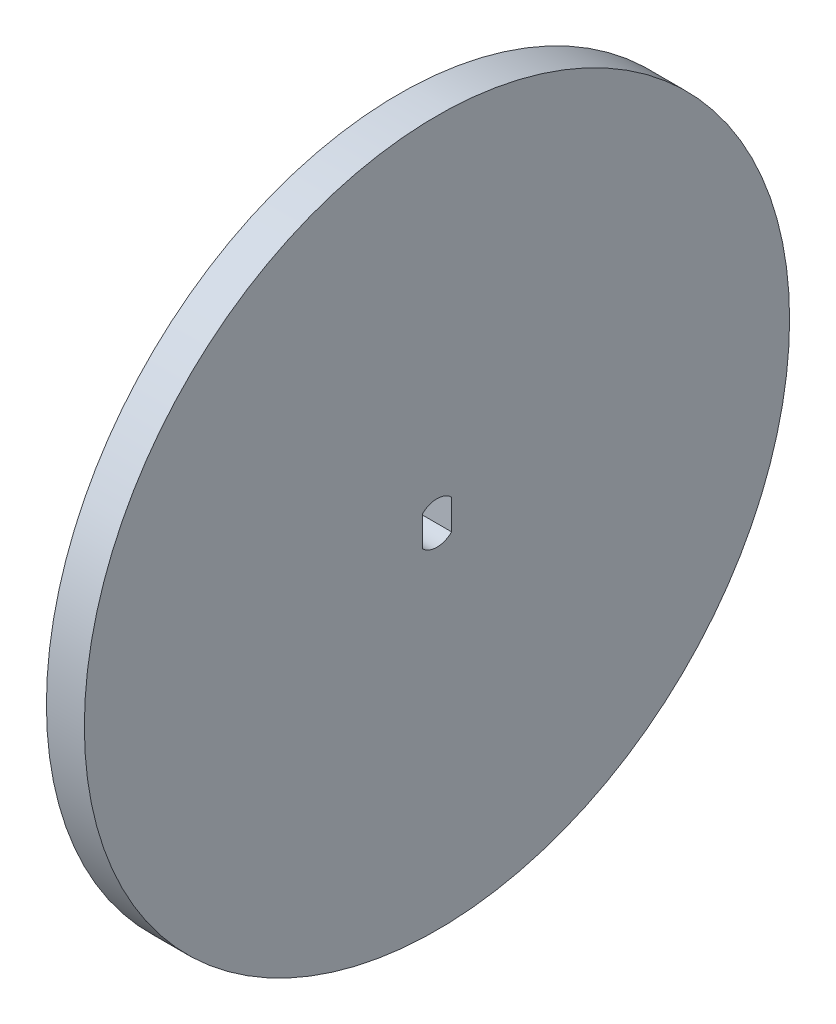
from build123d import *

# Parameters (mm, degrees)
CROQUIS1_R              = 45
SALIENTE_EXTRUIR1_DEPTH = 4.84


with BuildPart() as part:
    # Croquis1 → Saliente-Extruir1 (new body)
    with BuildSketch(Plane(origin=(0, 0, 0), x_dir=(0, 0, -1), z_dir=(1, 0, 0))):
        Circle(CROQUIS1_R)
        with BuildLine():
            Line((-1.87, 1.919765611), (-1.87, -1.919765611))
            ThreePointArc((-1.87, -1.919765611), (0, -2.68), (1.87, -1.919765611))
            Line((1.87, -1.919765611), (1.87, 1.919765611))
            ThreePointArc((1.87, 1.919765611), (0, 2.68), (-1.87, 1.919765611))
        make_face(mode=Mode.SUBTRACT)
    extrude(amount=SALIENTE_EXTRUIR1_DEPTH)


solid = part.part
